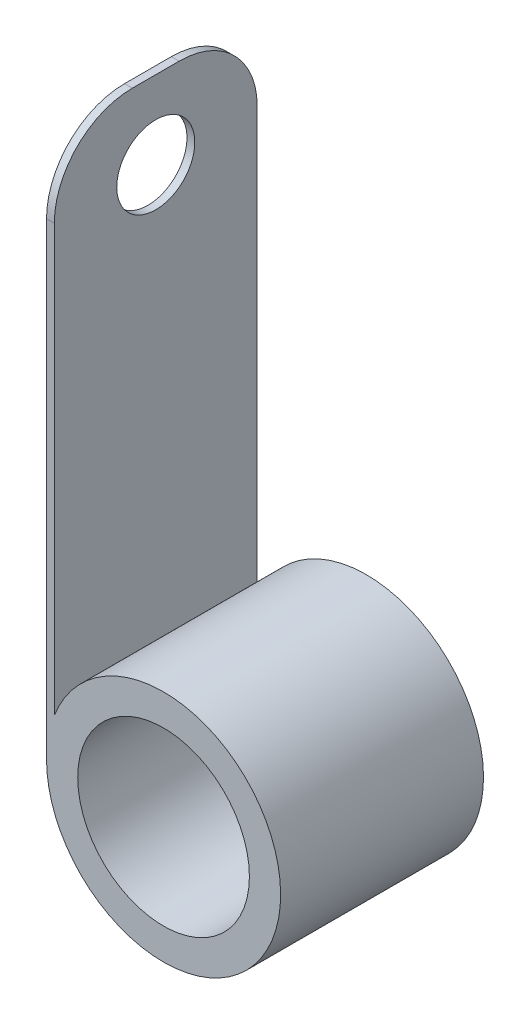
from build123d import *

# Parameters (mm, degrees)
ESBO_O1_R                = 7.5
ESBO_O1_R_2              = 5.5
RESSALTO_EXTRUS_O1_DEPTH = 13
ESBO_O2_W                = 0.5
ESBO_O2_H                = 13
RESSALTO_EXTRUS_O2_DEPTH = 35
ESBO_O3_R                = 2.5
CORTE_EXTRUS_O1_DEPTH    = 20
FILETE1_R                = 5


with BuildPart() as part:
    # Esboço1 → Ressalto-extrusão1 (new body)
    with BuildSketch(Plane.XY):
        Circle(ESBO_O1_R)
        Circle(ESBO_O1_R_2, mode=Mode.SUBTRACT)
    extrude(amount=RESSALTO_EXTRUS_O1_DEPTH)

    # Esboço2 → Ressalto-extrusão2 (add)
    with BuildSketch(Plane(origin=(0, 0, 0), x_dir=(1, 0, 0), z_dir=(0, 1, 0))):
        with Locations((-7.25, -6.5)):
            Rectangle(ESBO_O2_W, ESBO_O2_H)
    extrude(amount=RESSALTO_EXTRUS_O2_DEPTH)

    # Esboço3 → Corte-extrusão1 (cut)
    with BuildSketch(Plane.ZY.offset(7.5)):
        with Locations((6.5, 30)):
            Circle(ESBO_O3_R)
    extrude(amount=-CORTE_EXTRUS_O1_DEPTH, mode=Mode.SUBTRACT)

    # Filete1
    filete1_edges = [part.edges().sort_by_distance(p)[0] for p in [
        (-7.25, 35, 13),
        (-7.25, 35, 0),
    ]]
    fillet(filete1_edges, radius=FILETE1_R)


solid = part.part
